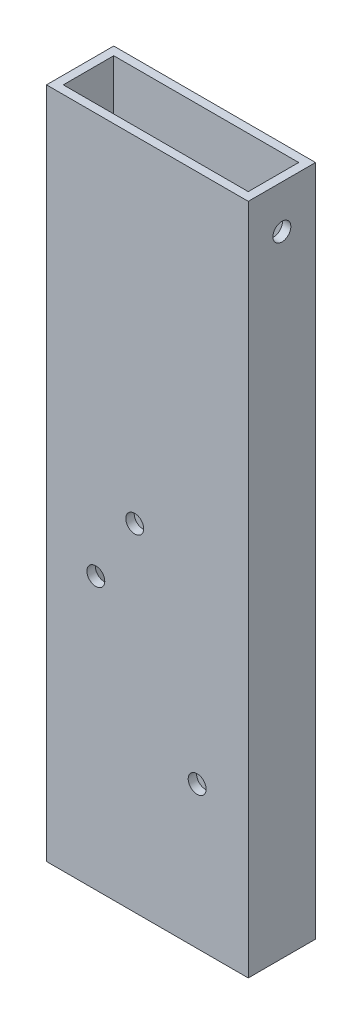
from build123d import *

# Parameters (mm, degrees)
SKETCH1_W               = 76.2
SKETCH1_H               = 25.4
SKETCH1_W_2             = 69.85
SKETCH1_H_2             = 19.05
BOSS_EXTRUDE1_DEPTH     = 254
SKETCH3_R               = 3.3782
CUT_EXTRUDE1_DEPTH      = 26.4
SKETCH4_R               = 3.3782
CUT_EXTRUDE2_DEPTH      = 1
CUT_EXTRUDE2_DEPTH_BACK = 77.2


with BuildPart() as part:
    # Sketch1 → Boss-Extrude1 (new body)
    with BuildSketch(Plane(origin=(0, 0, 0), x_dir=(1, 0, 0), z_dir=(0, 1, 0))):
        with Locations((38.1, 12.7)):
            Rectangle(SKETCH1_W, SKETCH1_H)
        with Locations((38.1, 12.7)):
            Rectangle(SKETCH1_W_2, SKETCH1_H_2, mode=Mode.SUBTRACT)
    extrude(amount=BOSS_EXTRUDE1_DEPTH)

    # Sketch3 → Cut-Extrude1 (cut, through all)
    with BuildSketch(Plane.XY):
        with Locations((56.897712706, 53.783695383)):
            Circle(SKETCH3_R)
        with Locations((18.636431119, 102.638247629)):
            Circle(SKETCH3_R)
        with Locations((33.330604718, 127.14563197)):
            Circle(SKETCH3_R)
    extrude(amount=-CUT_EXTRUDE1_DEPTH, mode=Mode.SUBTRACT)

    # Sketch4 → Cut-Extrude2 (cut, two sides)
    with BuildSketch(Plane.ZY) as cut_extrude2_sk:
        with Locations((-12.7, 237.7313)):
            Circle(SKETCH4_R)
    extrude(amount=CUT_EXTRUDE2_DEPTH, mode=Mode.SUBTRACT)
    extrude(cut_extrude2_sk.sketch, amount=-CUT_EXTRUDE2_DEPTH_BACK, mode=Mode.SUBTRACT)


solid = part.part
